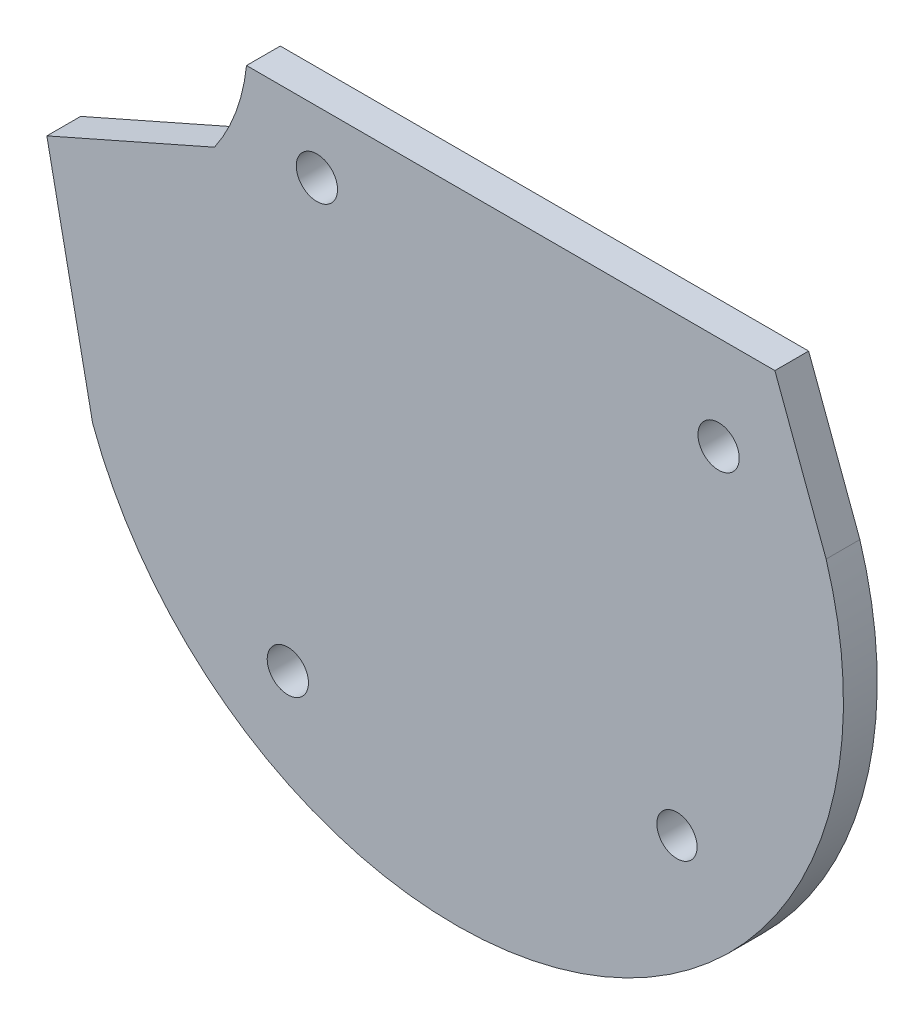
from build123d import *

# Parameters (mm, degrees)
SKETCH5_R      = 1.397
SKETCH5_R_2    = 1.362219034
EXTRUDE1_DEPTH = 2.286


with BuildPart() as part:
    # Sketch5 → Extrude1 (new body)
    with BuildSketch(Plane(origin=(0, 0, 0), x_dir=(-0.018375543, 0.999831155, 0), z_dir=(0, 0, -1))):
        with BuildLine():
            Line((33.80665155, 26.18621859), (34.46394605, -9.577814671))
            ThreePointArc((34.46394605, -9.577814671), (31.404055355, -10.348947358), (28.630167887, -11.853315998))
            Line((28.630167887, -11.853315998), (23.830153765, -23.292701447))
            Line((23.830153765, -23.292701447), (8.486225874, -20.477486777))
            ThreePointArc((8.486225874, -20.477486777), (-7.865336256, 12.262044577), (24.425706506, 29.482353943))
            Line((24.425706506, 29.482353943), (33.80665155, 26.18621859))
        make_face()
        with Locations((27.527734531, 22.260177192)):
            Circle(SKETCH5_R, mode=Mode.SUBTRACT)
        with Locations((30.179746314, -4.890797216)):
            Circle(SKETCH5_R, mode=Mode.SUBTRACT)
        with Locations((3.363138785, 18.996048152)):
            Circle(SKETCH5_R_2, mode=Mode.SUBTRACT)
        with Locations((0.317842079, -7.407837933)):
            Circle(SKETCH5_R, mode=Mode.SUBTRACT)
    extrude(amount=EXTRUDE1_DEPTH)


solid = part.part
